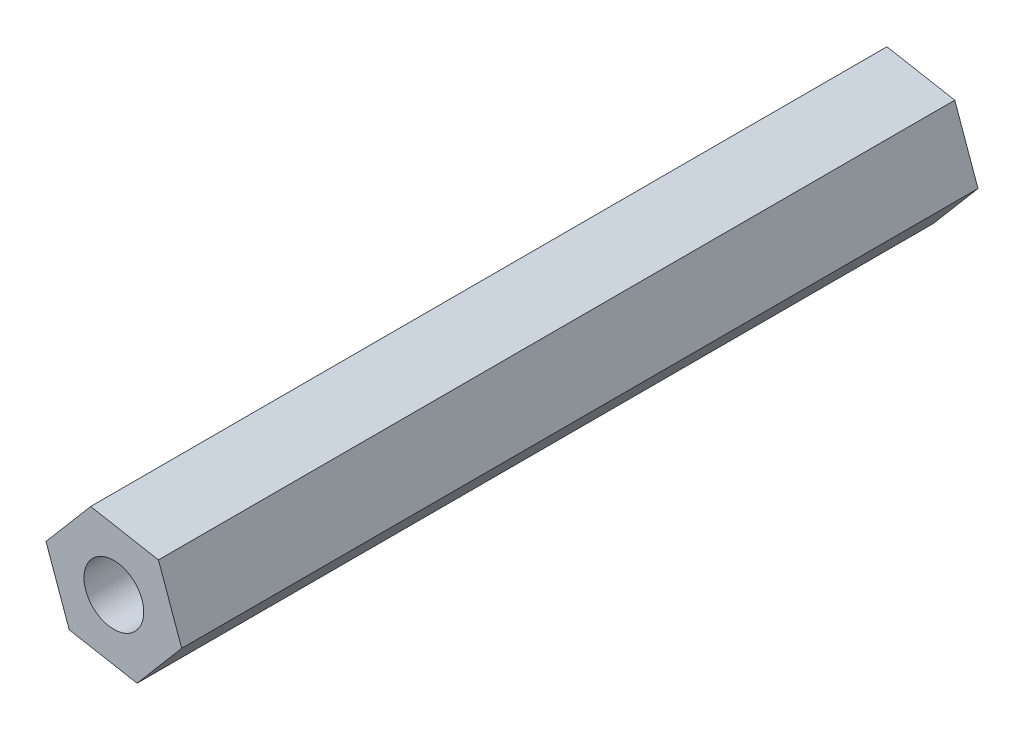
from build123d import *

# Parameters (mm, degrees)
RESSALTO_EXTRUS_O1_DEPTH = 40
ESBO_O4_R                = 1.5
CORTE_EXTRUS_O2_DEPTH    = 40


with BuildPart() as part:
    # Esboço1 → Ressalto-extrusão1 (new body)
    with BuildSketch(Plane.XY):
        Polygon((12.933175524, -4.143885809), (9.525050306, -3.523658029), (7.283854683, -6.165067156), (8.450784277, -9.426704064), (11.858909495, -10.046931845), (14.100105118, -7.405522718), align=None)
    extrude(amount=RESSALTO_EXTRUS_O1_DEPTH)

    # Esboço4 → Corte-extrusão2 (cut)
    with BuildSketch(Plane(origin=(0, 0, 0), x_dir=(-1, 0, 0), z_dir=(0, 0, -1))):
        with Locations((-10.691979901, -6.785294937)):
            Circle(ESBO_O4_R)
    extrude(amount=-CORTE_EXTRUS_O2_DEPTH, mode=Mode.SUBTRACT)


solid = part.part
